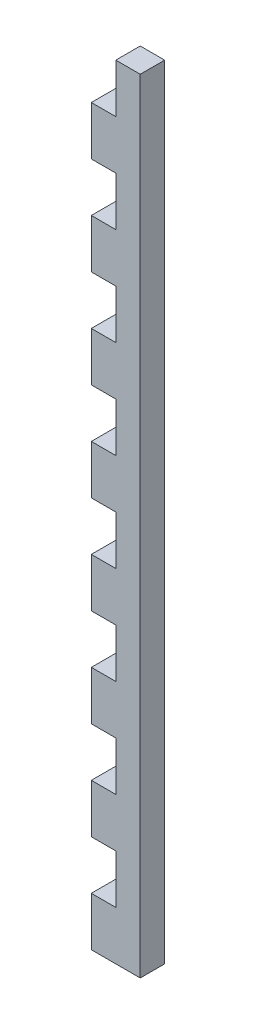
from build123d import *

# Parameters (mm, degrees)
SALIENTE_EXTRUIR1_DEPTH = 5


with BuildPart() as part:
    # Croquis1 → Saliente-Extruir1 (new body)
    with BuildSketch(Plane.XY):
        Polygon((-10.50310955, 63.111111111), (-10.50310955, 53.111111111), (-5.50310955, 53.111111111), (-5.50310955, 43.111111111), (-10.50310955, 43.111111111), (-10.50310955, 33.111111111), (-5.50310955, 33.111111111), (-5.50310955, 23.111111111), (-10.50310955, 23.111111111), (-10.50310955, 13.111111111), (-5.50310955, 13.111111111), (-5.50310955, 3.111111111), (-10.50310955, 3.111111111), (-10.50310955, -6.888888889), (-5.50310955, -6.888888889), (-5.50310955, -16.888888889), (-10.50310955, -16.888888889), (-10.50310955, -26.888888889), (-5.50310955, -26.888888889), (-5.50310955, -36.888888889), (-10.50310955, -36.888888889), (-10.50310955, -46.888888889), (-5.50310955, -46.888888889), (-5.50310955, -56.888888889), (-10.50310955, -56.888888889), (-10.50310955, -66.888888889), (-5.50310955, -66.888888889), (-5.50310955, -76.888888889), (-10.50310955, -76.888888889), (-10.50310955, -86.888888889), (-0.50310955, -86.888888889), (-0.50310955, 73.111111111), (-5.50310955, 73.111111111), (-5.50310955, 63.111111111), align=None)
    extrude(amount=SALIENTE_EXTRUIR1_DEPTH)


solid = part.part
